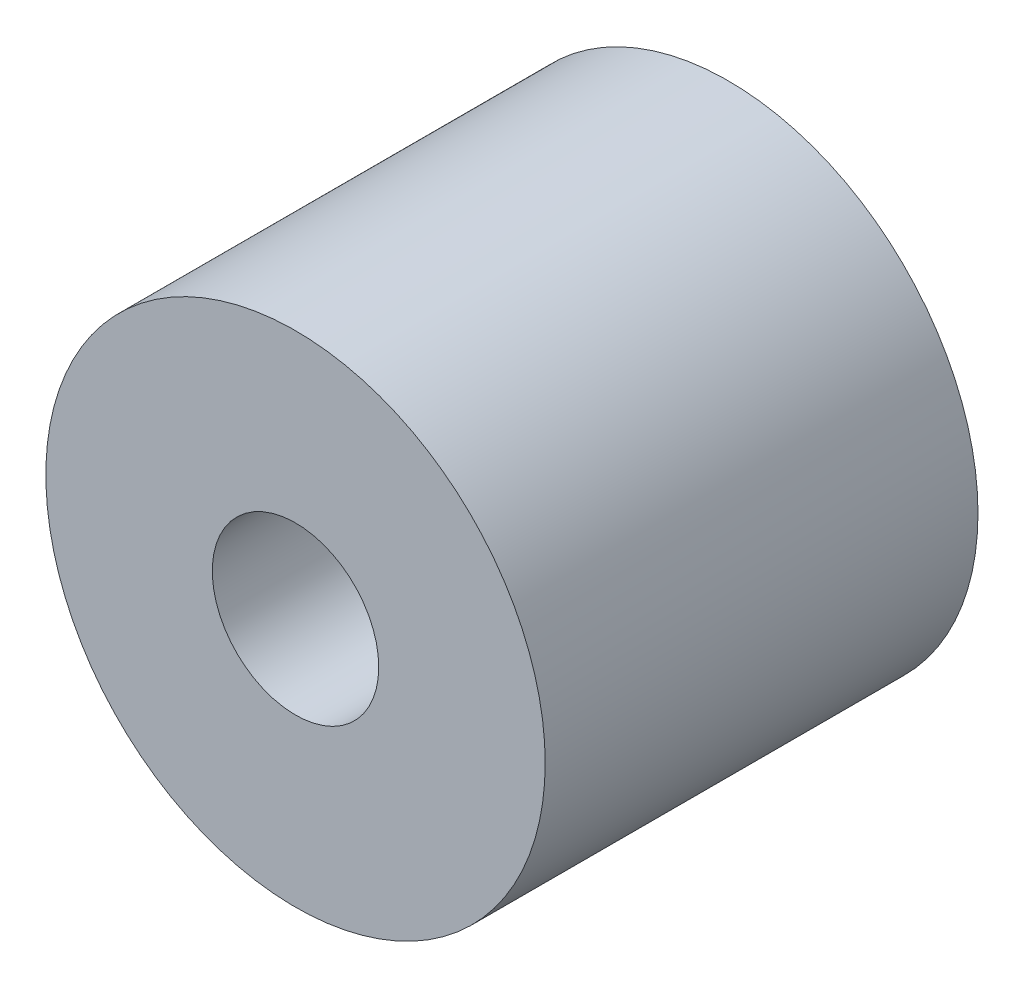
from build123d import *

# Parameters (mm, degrees)
SKETCH1_R           = 75
SKETCH1_R_2         = 25
BOSS_EXTRUDE1_DEPTH = 130


with BuildPart() as part:
    # Sketch1 → Boss-Extrude1 (new body)
    with BuildSketch(Plane.XY):
        Circle(SKETCH1_R)
        Circle(SKETCH1_R_2, mode=Mode.SUBTRACT)
    extrude(amount=BOSS_EXTRUDE1_DEPTH)


solid = part.part
